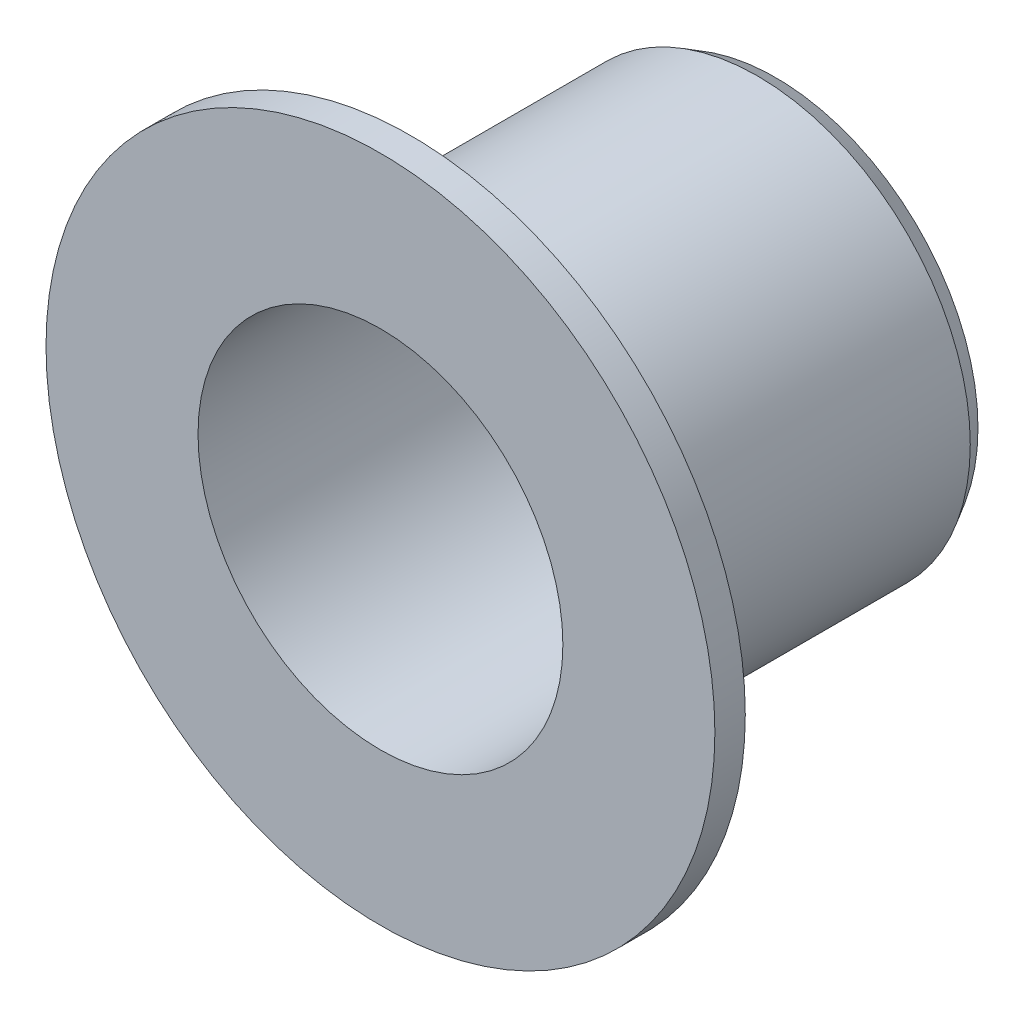
from build123d import *

# Parameters (mm, degrees)
ESBO_O1_R                = 3.5
ESBO_O1_R_2              = 3
RESSALTO_EXTRUS_O1_DEPTH = 5.5
ESBO_O2_R                = 3.5
ESBO_O2_R_2              = 3
RESSALTO_EXTRUS_O2_DEPTH = 0.5
ESBO_O3_R                = 5.5
ESBO_O3_R_2              = 3
RESSALTO_EXTRUS_O4_DEPTH = 0.5
FILETE1_R                = 0.5
CHANFRO1_SIZE            = 0.3
CHANFRO1_SIZE2           = 0.173205081


with BuildPart() as part:
    # Esboço1 → Ressalto-extrusão1 (new body)
    with BuildSketch(Plane.XY):
        Circle(ESBO_O1_R)
        Circle(ESBO_O1_R_2, mode=Mode.SUBTRACT)
    extrude(amount=RESSALTO_EXTRUS_O1_DEPTH)

    # Esboço2 → Ressalto-extrusão2 (add)
    with BuildSketch(Plane(origin=(0, 0, 0), x_dir=(-1, 0, 0), z_dir=(0, 0, -1))):
        Circle(ESBO_O2_R)
        Circle(ESBO_O2_R_2, mode=Mode.SUBTRACT)
    extrude(amount=RESSALTO_EXTRUS_O2_DEPTH)

    # Esboço3 → Ressalto-extrusão4 (add)
    with BuildSketch(Plane.XY.offset(5.5)):
        Circle(ESBO_O3_R)
        Circle(ESBO_O3_R_2, mode=Mode.SUBTRACT)
    extrude(amount=RESSALTO_EXTRUS_O4_DEPTH)

    # Filete1
    filete1_edges = [part.edges().sort_by_distance(p)[0] for p in [
        (-3.5, 0, 5.5),
    ]]
    fillet(filete1_edges, radius=FILETE1_R)

    # Chanfro1
    chanfro1_edges = [part.edges().sort_by_distance(p)[0] for p in [
        (3.5, 0, -0.5),
    ]]
    chanfro1_side = [part.faces().sort_by_distance(p)[0] for p in [
        (3.5, 0, -0.25),
    ]]
    chamfer(chanfro1_edges, length=CHANFRO1_SIZE, length2=CHANFRO1_SIZE2, reference=chanfro1_side[0])


solid = part.part
